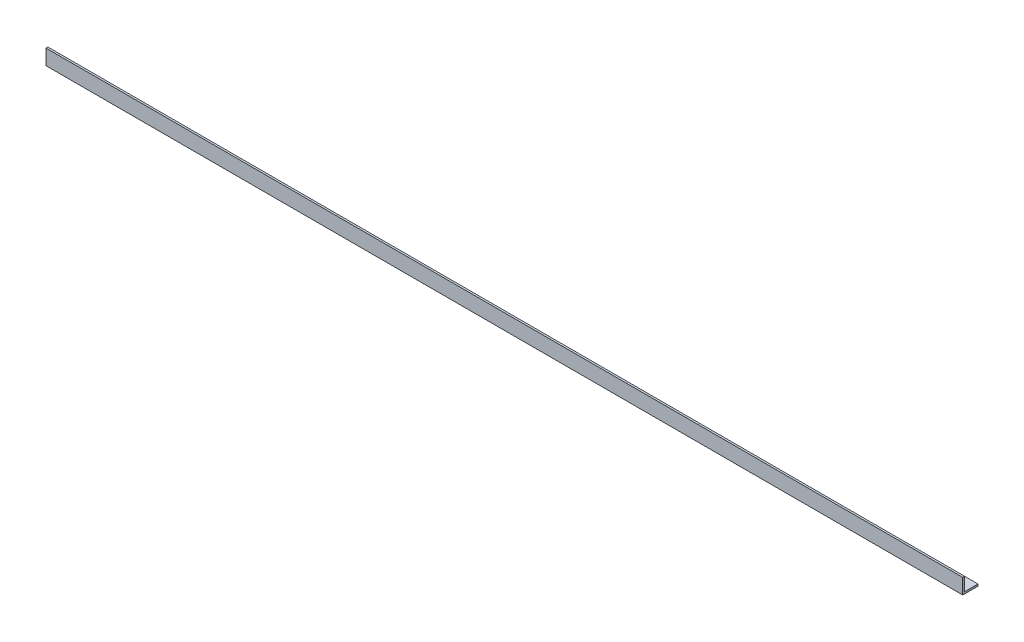
from build123d import *

# Parameters (mm, degrees)
BOSS_EXTRUDE2_DEPTH = 762


with BuildPart() as part:
    # Sketch2 → Boss-Extrude2 (new body, symmetric)
    with BuildSketch(Plane(origin=(0, 0, 0), x_dir=(0, 0, -1), z_dir=(1, 0, 0))):
        Polygon((0, 0), (0, 25.4), (3.175, 25.4), (3.175, 3.175), (25.4, 3.175), (25.4, 0), align=None)
    extrude(amount=BOSS_EXTRUDE2_DEPTH, both=True)


solid = part.part
